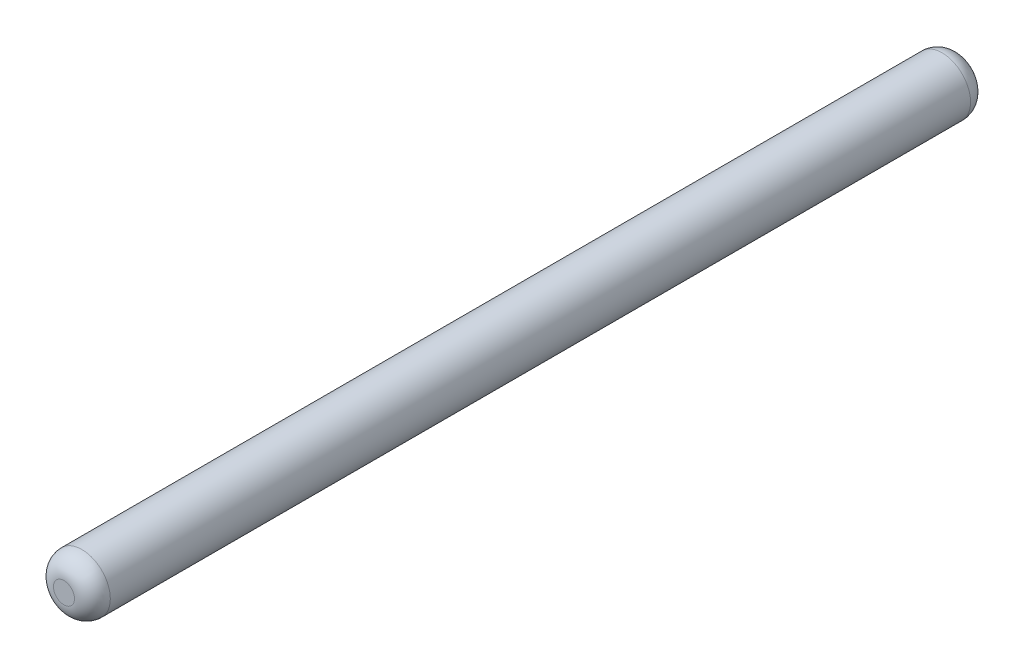
from build123d import *

# Parameters (mm, degrees)
SKETCH1_R           = 3.175
BOSS_EXTRUDE1_DEPTH = 100
FILLET1_R           = 2


with BuildPart() as part:
    # Sketch1 → Boss-Extrude1 (new body)
    with BuildSketch(Plane.XY):
        Circle(SKETCH1_R)
    extrude(amount=BOSS_EXTRUDE1_DEPTH)

    # Fillet1
    fillet1_edges = [part.edges().sort_by_distance(p)[0] for p in [
        (-3.175, 0, 0),
        (-3.175, 0, 100),
    ]]
    fillet(fillet1_edges, radius=FILLET1_R)


solid = part.part
